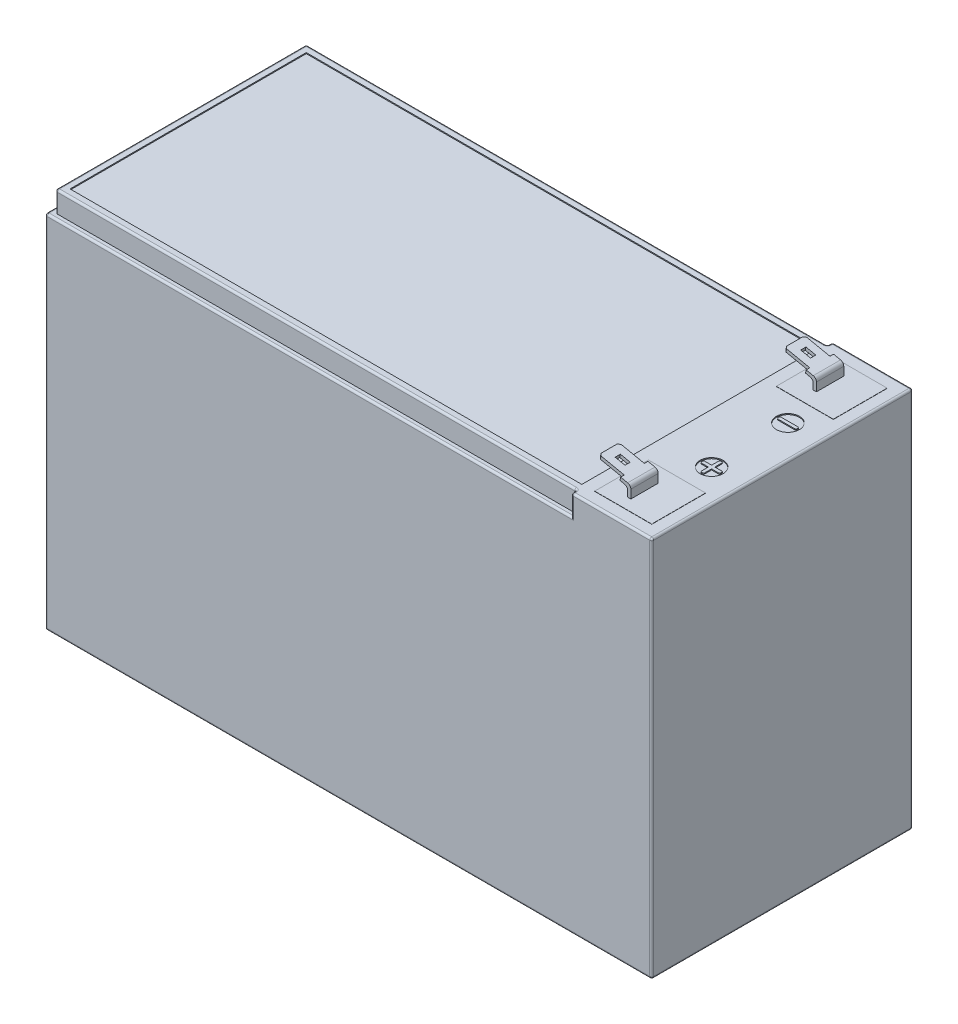
from build123d import *

# Parameters (mm, degrees)
SKETCH1_W                = 151
SKETCH1_H                = 65
BOSS_EXTRUDE1_DEPTH      = 95
BOSS_EXTRUDE2_DEPTH      = 6.8
SKETCH4_W                = 6.4
SKETCH4_H                = 0.9
SKETCH4_W_2              = 2.5
SKETCH4_H_2              = 1.3
CUT_EXTRUDE1_DEPTH       = 0.8
CHAMFER1_SIZE            = 0.5
FILLET1_R                = 1
CHAMFER1_OF_MIRROR1_SIZE = 0.5
FILLET1_OF_MIRROR1_R     = 1
CUT_EXTRUDE2_DEPTH       = 5.2
FILLET2_R                = 0.5
SKETCH6_R                = 2.875
SKETCH6_W                = 127.4
SKETCH6_H                = 58.8
SKETCH6_W_2              = 14.2
SKETCH6_H_2              = 13.4
CUT_EXTRUDE3_DEPTH       = 0.25
SKETCH7_W                = 14.2
SKETCH7_H                = 13.4
BOSS_EXTRUDE3_DEPTH      = 0.3
SKETCH8_W                = 14.2
SKETCH8_H                = 13.4
BOSS_EXTRUDE4_DEPTH      = 0.3
BOSS_EXTRUDE5_DEPTH      = 0.5
MIRROR3_COPY_1_DEPTH     = 0.5


with BuildPart() as part:
    # Sketch1 → Boss-Extrude1 (new body)
    with BuildSketch(Plane(origin=(0, 0, 0), x_dir=(1, 0, 0), z_dir=(0, 1, 0))):
        with Locations((0.44359577, 11.061104583)):
            Rectangle(SKETCH1_W, SKETCH1_H)
    extrude(amount=BOSS_EXTRUDE1_DEPTH)

    # Sketch2 → Boss-Extrude2 (add)
    with BuildSketch(Plane.XY.offset(15.438895417)):
        Polygon((63.94359577, 95), (63.94359577, 97.325729645), (55.769774606, 99.029953582), (55.933061472, 99.813112186), (64.74359577, 97.976134945), (64.74359577, 95), align=None)
    boss_extrude2 = extrude(amount=-BOSS_EXTRUDE2_DEPTH)

    # Sketch4 → Cut-Extrude1 (cut)
    with BuildSketch(Plane(origin=(22.274020552, 106.830949022, 0), x_dir=(0.978948255, -0.204108582, 0), z_dir=(0.204108582, 0.978948255, 0))):
        with Locations((37.582860112, -9.088895417)):
            Rectangle(SKETCH4_W, SKETCH4_H)
        with Locations((37.582860112, -14.988895417)):
            Rectangle(SKETCH4_W, SKETCH4_H)
        with Locations((37.832860112, -12.038895417)):
            Rectangle(SKETCH4_W_2, SKETCH4_H_2)
    cut_extrude1 = extrude(amount=-CUT_EXTRUDE1_DEPTH, mode=Mode.SUBTRACT)

    # Chamfer1
    chamfer1_edges = [part.edges().sort_by_distance(p)[0] for p in [
        (55.851418039, 99.421532884, 9.538895417),
        (55.851418039, 99.421532884, 14.538895417),
    ]]
    chamfer(chamfer1_edges, length=CHAMFER1_SIZE)

    # Fillet1
    fillet1_edges = [part.edges().sort_by_distance(p)[0] for p in [
        (63.94359577, 97.325729645, 12.038895417),
        (64.74359577, 97.976134945, 12.038895417),
    ]]
    fillet(fillet1_edges, radius=FILLET1_R)

    # Mirror1: Boss-Extrude2, Cut-Extrude1 across plane
    add(boss_extrude2.mirror(Plane.XY.offset(-11.061104583)))
    add(cut_extrude1.mirror(Plane.XY.offset(-11.061104583)), mode=Mode.SUBTRACT)

    # Chamfer1 of Mirror1
    chamfer1_of_mirror1_edges = [part.edges().sort_by_distance(p)[0] for p in [
        (55.851418039, 99.421532884, -31.661104583),
        (55.851418039, 99.421532884, -36.661104583),
    ]]
    chamfer(chamfer1_of_mirror1_edges, length=CHAMFER1_OF_MIRROR1_SIZE)

    # Fillet1 of Mirror1
    fillet1_of_mirror1_edges = [part.edges().sort_by_distance(p)[0] for p in [
        (63.94359577, 97.325729645, -34.161104583),
        (64.74359577, 97.976134945, -34.161104583),
    ]]
    fillet(fillet1_of_mirror1_edges, radius=FILLET1_OF_MIRROR1_R)

    # Sketch5 → Cut-Extrude2 (cut)
    with BuildSketch(Plane(origin=(0, 95, 0), x_dir=(1, 0, 0), z_dir=(0, 1, 0))):
        Polygon((55.94359577, -21.438895417), (55.94359577, -20.138895417), (-73.75640423, -20.138895417), (-73.75640423, 42.261104583), (55.94359577, 42.261104583), (55.94359577, 43.561104583), (-75.05640423, 43.561104583), (-75.05640423, -21.438895417), align=None)
    extrude(amount=-CUT_EXTRUDE2_DEPTH, mode=Mode.SUBTRACT)

    # Fillet2
    fillet2_edges = [part.edges().sort_by_distance(p)[0] for p in [
        (75.94359577, 95, -11.061104583),
        (65.94359577, 95, -43.561104583),
        (65.94359577, 95, 21.438895417),
        (-75.05640423, 44.9, -43.561104583),
        (-75.05640423, 44.9, 21.438895417),
        (-9.55640423, 89.8, 21.438895417),
        (55.94359577, 92.4, 21.438895417),
        (-75.05640423, 89.8, -11.061104583),
        (-9.55640423, 89.8, -43.561104583),
        (55.94359577, 92.4, -43.561104583),
        (55.94359577, 92.4, -42.261104583),
        (-73.75640423, 92.4, -42.261104583),
        (-73.75640423, 92.4, 20.138895417),
        (55.94359577, 92.4, 20.138895417),
        (55.94359577, 95, 20.788895417),
        (-8.90640423, 95, 20.138895417),
        (-73.75640423, 95, -11.061104583),
        (-8.90640423, 95, -42.261104583),
        (55.94359577, 95, -42.911104583),
        (0.44359577, 0, -43.561104583),
        (75.94359577, 0, -11.061104583),
        (0.44359577, 0, 21.438895417),
        (-75.05640423, 0, -11.061104583),
        (75.94359577, 47.5, -43.561104583),
        (75.94359577, 47.5, 21.438895417),
    ]]
    fillet(fillet2_edges, radius=FILLET2_R)

    # Sketch6 → Cut-Extrude3 (cut)
    with BuildSketch(Plane(origin=(0, 95, 0), x_dir=(1, 0, 0), z_dir=(0, 1, 0))):
        with Locations((67.84359577, 20.561104583)):
            Circle(SKETCH6_R)
        with BuildLine():
            Line((65.69359577, 20.961104583), (69.99359577, 20.961104583))
            ThreePointArc((69.99359577, 20.961104583), (70.170372465, 20.887881278), (70.24359577, 20.711104583))
            Line((70.24359577, 20.711104583), (70.24359577, 20.411104583))
            ThreePointArc((70.24359577, 20.411104583), (70.170372465, 20.234327888), (69.99359577, 20.161104583))
            Line((69.99359577, 20.161104583), (65.69359577, 20.161104583))
            ThreePointArc((65.69359577, 20.161104583), (65.516819074, 20.234327888), (65.44359577, 20.411104583))
            Line((65.44359577, 20.411104583), (65.44359577, 20.711104583))
            ThreePointArc((65.44359577, 20.711104583), (65.516819074, 20.887881278), (65.69359577, 20.961104583))
        make_face(mode=Mode.SUBTRACT)
        with Locations((67.84359577, 1.561104583)):
            Circle(SKETCH6_R)
        with BuildLine():
            Line((67.44359577, 3.711104583), (67.44359577, 1.961104583))
            Line((67.44359577, 1.961104583), (65.69359577, 1.961104583))
            ThreePointArc((65.69359577, 1.961104583), (65.516819074, 1.887881278), (65.44359577, 1.711104583))
            Line((65.44359577, 1.711104583), (65.44359577, 1.411104583))
            ThreePointArc((65.44359577, 1.411104583), (65.516819074, 1.234327888), (65.69359577, 1.161104583))
            Line((65.69359577, 1.161104583), (67.44359577, 1.161104583))
            Line((67.44359577, 1.161104583), (67.44359577, -0.588895417))
            ThreePointArc((67.44359577, -0.588895417), (67.516819074, -0.765672112), (67.69359577, -0.838895417))
            Line((67.69359577, -0.838895417), (67.99359577, -0.838895417))
            ThreePointArc((67.99359577, -0.838895417), (68.170372465, -0.765672112), (68.24359577, -0.588895417))
            Line((68.24359577, -0.588895417), (68.24359577, 1.161104583))
            Line((68.24359577, 1.161104583), (69.99359577, 1.161104583))
            ThreePointArc((69.99359577, 1.161104583), (70.170372465, 1.234327888), (70.24359577, 1.411104583))
            Line((70.24359577, 1.411104583), (70.24359577, 1.711104583))
            ThreePointArc((70.24359577, 1.711104583), (70.170372465, 1.887881278), (69.99359577, 1.961104583))
            Line((69.99359577, 1.961104583), (68.24359577, 1.961104583))
            Line((68.24359577, 1.961104583), (68.24359577, 3.711104583))
            ThreePointArc((68.24359577, 3.711104583), (68.170372465, 3.887881278), (67.99359577, 3.961104583))
            Line((67.99359577, 3.961104583), (67.69359577, 3.961104583))
            ThreePointArc((67.69359577, 3.961104583), (67.516819074, 3.887881278), (67.44359577, 3.711104583))
        make_face(mode=Mode.SUBTRACT)
        with Locations((-8.25640423, 11.061104583)):
            Rectangle(SKETCH6_W, SKETCH6_H)
        with Locations((65.64359577, 33.661104583)):
            Rectangle(SKETCH6_W_2, SKETCH6_H_2)
        with Locations((65.64359577, -11.538895417)):
            Rectangle(SKETCH6_W_2, SKETCH6_H_2)
    extrude(amount=-CUT_EXTRUDE3_DEPTH, mode=Mode.SUBTRACT)

    # Sketch7 → Boss-Extrude3 (add)
    with BuildSketch(Plane(origin=(0, 94.75, 0), x_dir=(1, 0, 0), z_dir=(0, 1, 0))):
        with Locations((65.64359577, 33.661104583)):
            Rectangle(SKETCH7_W, SKETCH7_H)
    extrude(amount=BOSS_EXTRUDE3_DEPTH)

    # Sketch8 → Boss-Extrude4 (add)
    with BuildSketch(Plane(origin=(0, 94.75, 0), x_dir=(1, 0, 0), z_dir=(0, 1, 0))):
        with Locations((65.64359577, -11.538895417)):
            Rectangle(SKETCH8_W, SKETCH8_H)
    extrude(amount=BOSS_EXTRUDE4_DEPTH)

    # Sketch9 → Boss-Extrude5 (add)
    with BuildSketch(Plane.XZ):
        with BuildLine():
            Line((-70.05640423, 8.738895417), (-70.05640423, 15.938895417))
            ThreePointArc((-70.05640423, 15.938895417), (-69.909957621, 16.292448808), (-69.55640423, 16.438895417))
            Line((-69.55640423, 16.438895417), (-62.35640423, 16.438895417))
            ThreePointArc((-62.35640423, 16.438895417), (-62.00285084, 16.292448808), (-61.85640423, 15.938895417))
            Line((-61.85640423, 15.938895417), (-61.85640423, 14.938895417))
            ThreePointArc((-61.85640423, 14.938895417), (-62.00285084, 14.585342027), (-62.35640423, 14.438895417))
            Line((-62.35640423, 14.438895417), (-68.05640423, 14.438895417))
            Line((-68.05640423, 14.438895417), (-68.05640423, 8.738895417))
            ThreePointArc((-68.05640423, 8.738895417), (-68.20285084, 8.385342027), (-68.55640423, 8.238895417))
            Line((-68.55640423, 8.238895417), (-69.55640423, 8.238895417))
            ThreePointArc((-69.55640423, 8.238895417), (-69.909957621, 8.385342027), (-70.05640423, 8.738895417))
        make_face()
    boss_extrude5 = extrude(amount=BOSS_EXTRUDE5_DEPTH)

    # Mirror2: Boss-Extrude5 across plane
    add(boss_extrude5.mirror(Plane.ZY.offset(-0.44359577)))

    # Mirror3: Boss-Extrude5 across plane
    add(boss_extrude5.mirror(Plane.XY.offset(-11.061104583)))

    # Mirror3 copy 1 sketch → Mirror3 copy 1 (add)
    with BuildSketch(Plane(origin=(0.887191539, 0, -22.122209166), x_dir=(-1, 0, 0), z_dir=(0, -1, 0))):
        with BuildLine():
            Line((-70.05640423, 8.738895417), (-70.05640423, 15.938895417))
            ThreePointArc((-70.05640423, 15.938895417), (-69.909957621, 16.292448808), (-69.55640423, 16.438895417))
            Line((-69.55640423, 16.438895417), (-62.35640423, 16.438895417))
            ThreePointArc((-62.35640423, 16.438895417), (-62.00285084, 16.292448808), (-61.85640423, 15.938895417))
            Line((-61.85640423, 15.938895417), (-61.85640423, 14.938895417))
            ThreePointArc((-61.85640423, 14.938895417), (-62.00285084, 14.585342027), (-62.35640423, 14.438895417))
            Line((-62.35640423, 14.438895417), (-68.05640423, 14.438895417))
            Line((-68.05640423, 14.438895417), (-68.05640423, 8.738895417))
            ThreePointArc((-68.05640423, 8.738895417), (-68.20285084, 8.385342027), (-68.55640423, 8.238895417))
            Line((-68.55640423, 8.238895417), (-69.55640423, 8.238895417))
            ThreePointArc((-69.55640423, 8.238895417), (-69.909957621, 8.385342027), (-70.05640423, 8.738895417))
        make_face()
    extrude(amount=MIRROR3_COPY_1_DEPTH)


solid = part.part
